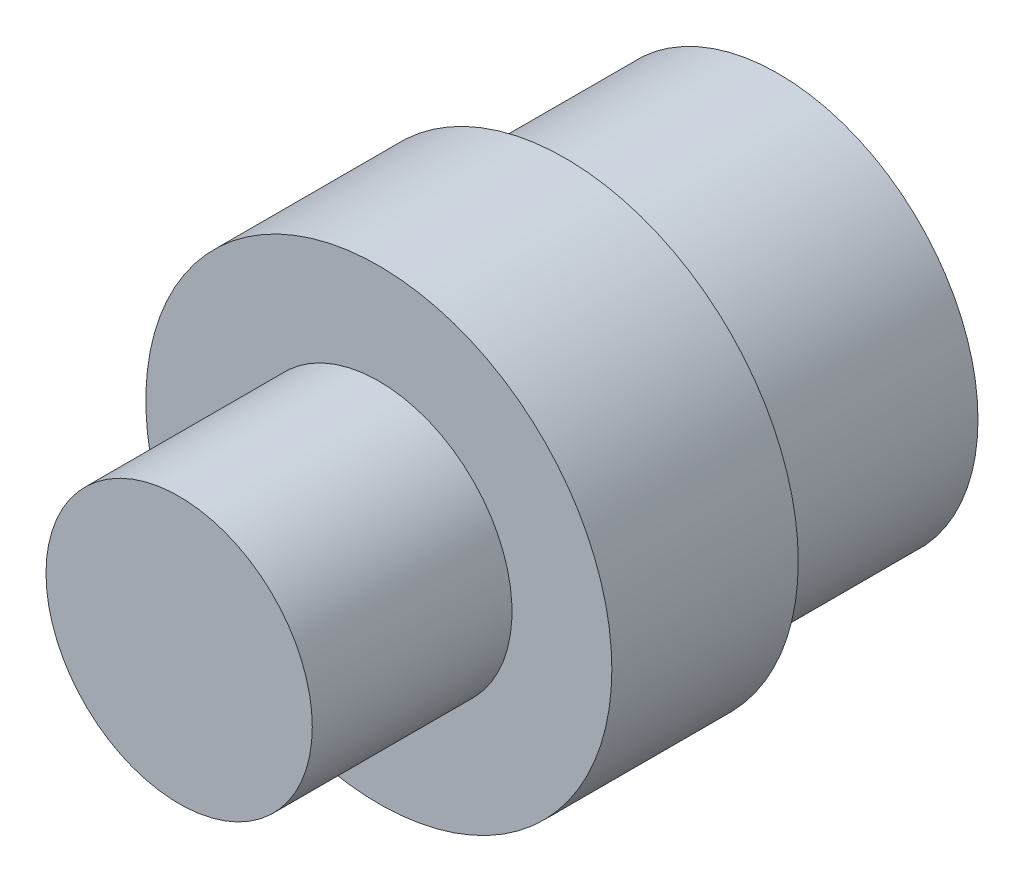
from build123d import *

# Parameters (mm, degrees)
SKETCH1_R      = 6.35
EXTRUDE1_DEPTH = 9.525
SKETCH2_R      = 9.525
EXTRUDE2_DEPTH = 19.05
SKETCH3_R      = 11.1125
EXTRUDE3_DEPTH = 8.89


with BuildPart() as part:
    # Sketch1 → Extrude1 (new body)
    with BuildSketch(Plane.XY):
        Circle(SKETCH1_R)
    extrude(amount=EXTRUDE1_DEPTH)

    # Sketch2 → Extrude2 (add)
    with BuildSketch(Plane(origin=(0, 0, 0), x_dir=(-1, 0, 0), z_dir=(0, 0, -1))):
        Circle(SKETCH2_R)
    extrude(amount=EXTRUDE2_DEPTH)

    # Sketch3 → Extrude3 (add)
    with BuildSketch(Plane.XY):
        Circle(SKETCH3_R)
    extrude(amount=-EXTRUDE3_DEPTH)


solid = part.part
